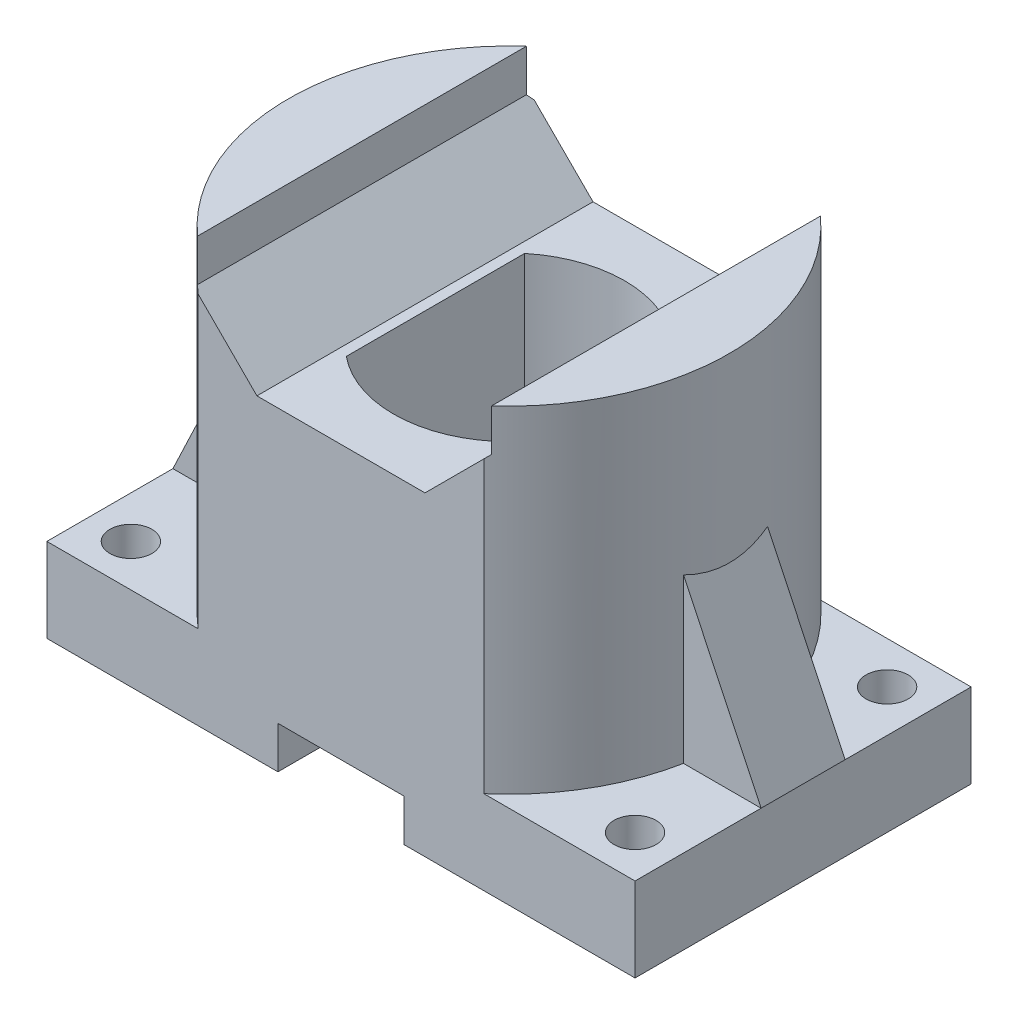
from build123d import *

# Parameters (mm, degrees)
SKETCH_1_W               = 140
SKETCH_1_H               = 80
SKETCH_1_R               = 5
EXTRUDE_1_DEPTH          = 20
EXTRUDE_2_DEPTH          = 80
CUT_EXTRUDE_1_DEPTH      = 65
CUT_EXTRUDE_2_DEPTH      = 41
CUT_EXTRUDE_2_DEPTH_BACK = 41
SKETCH_6_W               = 30
SKETCH_6_H               = 10
CUT_EXTRUDE_3_DEPTH      = 41
CUT_EXTRUDE_3_DEPTH_BACK = 41
SKETCH_7_R               = 25
CUT_EXTRUDE_4_DEPTH      = 35
EXTRUDE_3_DEPTH          = 10
EXTRUDE_3_DEPTH_BACK     = 10


with BuildPart() as part:
    # Эскиз1 → Бобышка-Вытянуть1 (new body)
    with BuildSketch(Plane(origin=(0, 0, 0), x_dir=(1, 0, 0), z_dir=(0, 1, 0))):
        Rectangle(SKETCH_1_W, SKETCH_1_H)
        with Locations((-60, 30)):
            Circle(SKETCH_1_R, mode=Mode.SUBTRACT)
        with Locations((60, 30)):
            Circle(SKETCH_1_R, mode=Mode.SUBTRACT)
        with Locations((60, -30)):
            Circle(SKETCH_1_R, mode=Mode.SUBTRACT)
        with Locations((-60, -30)):
            Circle(SKETCH_1_R, mode=Mode.SUBTRACT)
    extrude(amount=EXTRUDE_1_DEPTH)

    # Эскиз2 → Бобышка-Вытянуть2 (add)
    with BuildSketch(Plane(origin=(0, 20, 0), x_dir=(1, 0, 0), z_dir=(0, 1, 0))):
        with BuildLine():
            Line((-34.003676272, 40), (34.003676272, 40))
            ThreePointArc((34.003676272, 40), (52.5, 0), (34.003676272, -40))
            Line((34.003676272, -40), (-34.003676272, -40))
            ThreePointArc((-34.003676272, -40), (-52.5, 0), (-34.003676272, 40))
        make_face()
    extrude(amount=EXTRUDE_2_DEPTH)

    # Эскиз3 → Вырез-Вытянуть1 (cut)
    with BuildSketch(Plane(origin=(0, 100, 0), x_dir=(1, 0, 0), z_dir=(0, 1, 0))):
        with BuildLine():
            Line((17.5, -21.213203436), (17.5, 21.213203436))
            ThreePointArc((17.5, 21.213203436), (0, 27.5), (-17.5, 21.213203436))
            Line((-17.5, 21.213203436), (-17.5, -21.213203436))
            ThreePointArc((-17.5, -21.213203436), (0, -27.5), (17.5, -21.213203436))
        make_face()
    extrude(amount=-CUT_EXTRUDE_1_DEPTH, mode=Mode.SUBTRACT)

    # Эскиз5 → Вырез-Вытянуть2 (cut, two sides)
    with BuildSketch(Plane.XY) as cut_extrude_2_sk:
        Polygon((-20, 75), (20, 75), (35, 90), (35, 100), (-35, 100), (-35, 90), align=None)
    extrude(amount=CUT_EXTRUDE_2_DEPTH, mode=Mode.SUBTRACT)
    extrude(cut_extrude_2_sk.sketch, amount=-CUT_EXTRUDE_2_DEPTH_BACK, mode=Mode.SUBTRACT)

    # Эскиз6 → Вырез-Вытянуть3 (cut, two sides)
    with BuildSketch(Plane.XY) as cut_extrude_3_sk:
        with Locations((0, 5)):
            Rectangle(SKETCH_6_W, SKETCH_6_H)
    extrude(amount=CUT_EXTRUDE_3_DEPTH, mode=Mode.SUBTRACT)
    extrude(cut_extrude_3_sk.sketch, amount=-CUT_EXTRUDE_3_DEPTH_BACK, mode=Mode.SUBTRACT)

    # Эскиз7 → Вырез-Вытянуть4 (cut)
    with BuildSketch(Plane.XZ):
        Circle(SKETCH_7_R)
    extrude(amount=-CUT_EXTRUDE_4_DEPTH, mode=Mode.SUBTRACT)

    # Эскиз8 → Бобышка-Вытянуть3 (add, two sides)
    with BuildSketch(Plane.XY) as extrude_3_sk:
        Polygon((-70, 20), (-51, 60), (-51, 20), align=None)
        Polygon((51, 60), (51, 20), (70, 20), align=None)
    extrude(amount=EXTRUDE_3_DEPTH)
    extrude(extrude_3_sk.sketch, amount=-EXTRUDE_3_DEPTH_BACK)


solid = part.part
